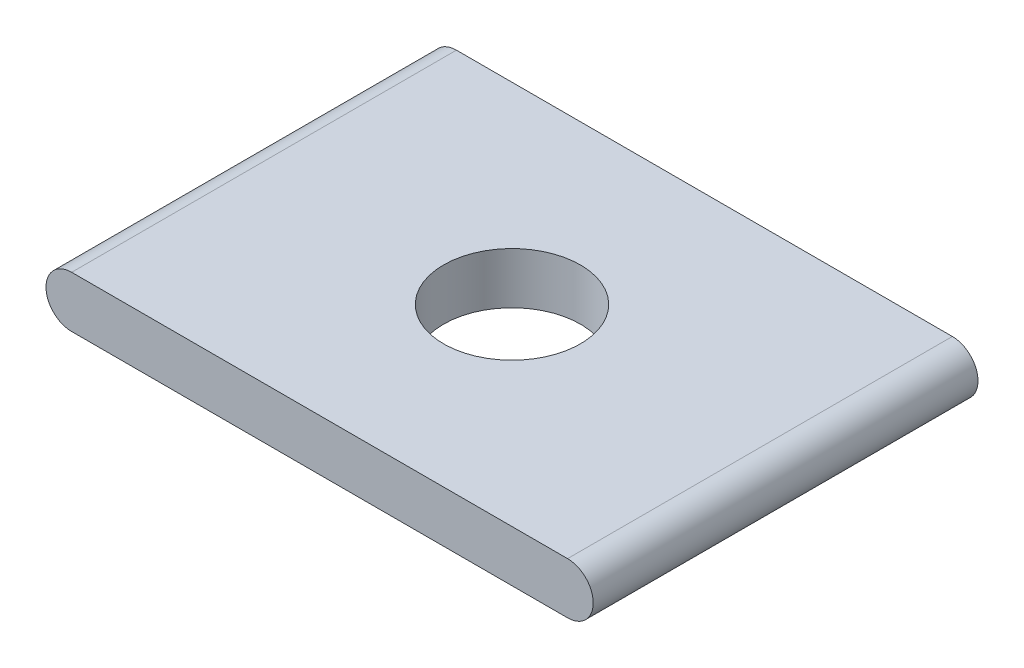
from build123d import *

# Parameters (mm, degrees)
MOUNT_DEPTH = 28.575
SKETCH2_R   = 5.08
HOLE_DEPTH  = 4.81


with BuildPart() as part:
    # Sketch1 → Mount (new body)
    with BuildSketch(Plane.XY):
        with BuildLine():
            Line((-18.415, 1.905), (18.415, 1.905))
            ThreePointArc((18.415, 1.905), (20.32, 0), (18.415, -1.905))
            Line((18.415, -1.905), (-18.415, -1.905))
            ThreePointArc((-18.415, -1.905), (-20.32, 0), (-18.415, 1.905))
        make_face()
    extrude(amount=MOUNT_DEPTH)

    # Sketch2 → Hole (cut, through all)
    with BuildSketch(Plane(origin=(0, 1.905, 0), x_dir=(1, 0, 0), z_dir=(0, 1, 0))):
        with Locations((0, -14.2875)):
            Circle(SKETCH2_R)
    extrude(amount=-HOLE_DEPTH, mode=Mode.SUBTRACT)


solid = part.part
